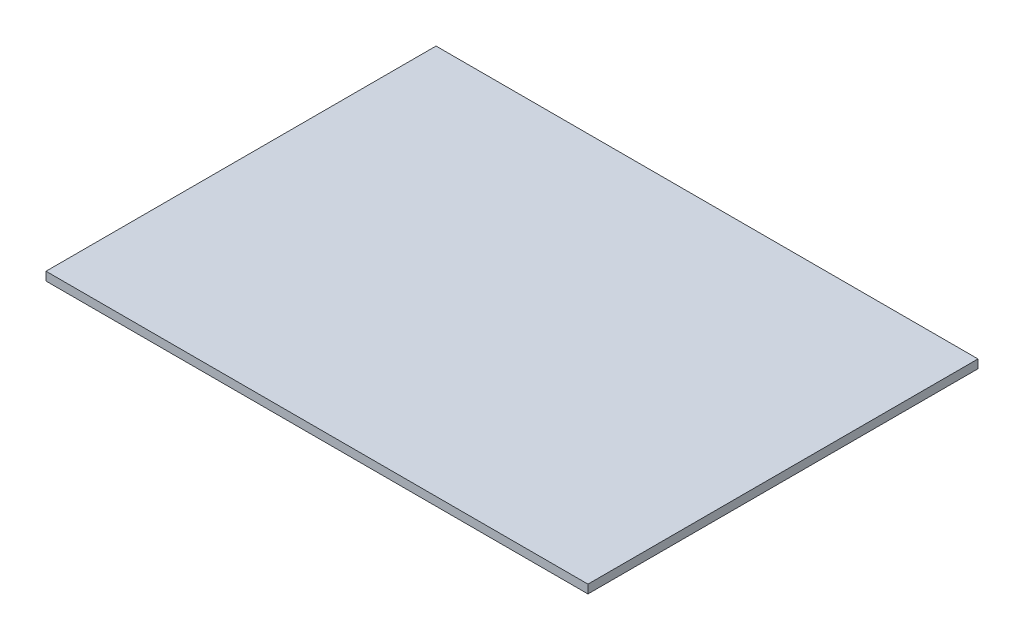
from build123d import *

# Parameters (mm, degrees)
SKETCH1_W           = 63.5
SKETCH1_H           = 45.7
BOSS_EXTRUDE1_DEPTH = 1


with BuildPart() as part:
    # Sketch1 → Boss-Extrude1 (new body)
    with BuildSketch(Plane(origin=(0, 0, 0), x_dir=(1, 0, 0), z_dir=(0, 1, 0))):
        with Locations((-26.992429349, -0.765992904)):
            Rectangle(SKETCH1_W, SKETCH1_H)
    extrude(amount=BOSS_EXTRUDE1_DEPTH)


solid = part.part
